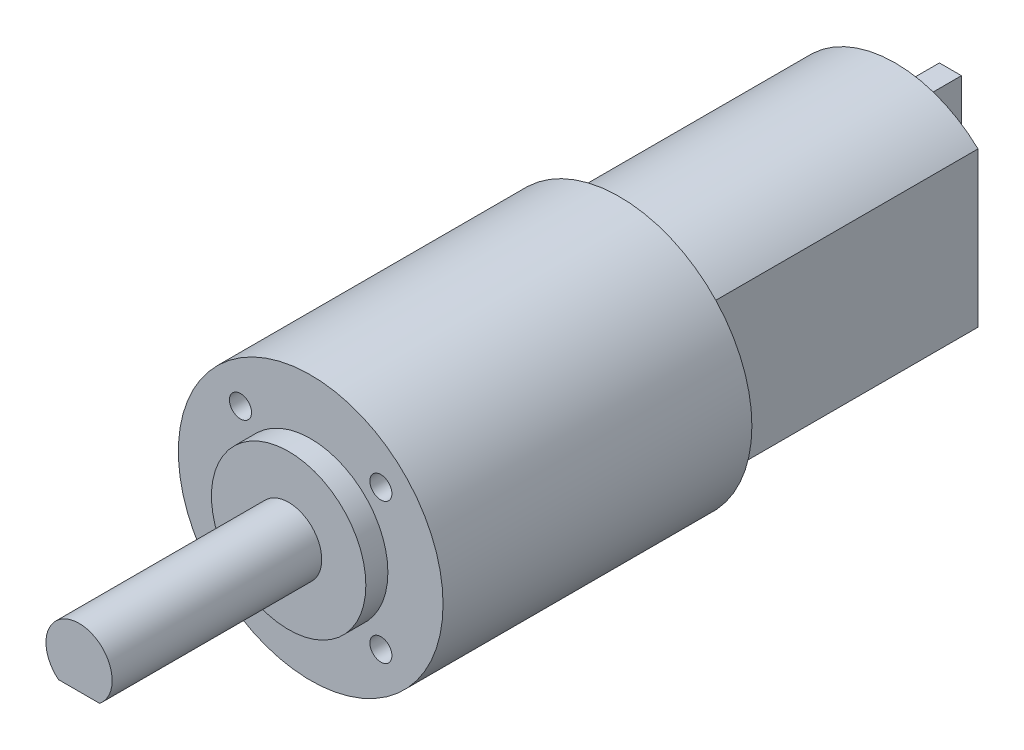
from build123d import *

# Parameters (mm, degrees)
BOSS_EXTRUDE1_DEPTH = 25
SKETCH2_W           = 2
SKETCH2_H           = 4
BOSS_EXTRUDE2_DEPTH = 5
SKETCH3_R           = 12
BOSS_EXTRUDE3_DEPTH = 28
SKETCH4_R           = 7
BOSS_EXTRUDE4_DEPTH = 2
SKETCH5_R           = 1
CUT_EXTRUDE1_DEPTH  = 5
BOSS_EXTRUDE5_DEPTH = 19


with BuildPart() as part:
    # Sketch1 → Boss-Extrude1 (new body)
    with BuildSketch(Plane.XY):
        with BuildLine():
            Line((7.5, -7), (7.5, 7))
            ThreePointArc((7.5, 7), (0, 10), (-7.5, 7))
            Line((-7.5, 7), (-7.5, -7))
            ThreePointArc((-7.5, -7), (0, -10), (7.5, -7))
        make_face()
    extrude(amount=BOSS_EXTRUDE1_DEPTH)

    # Sketch2 → Boss-Extrude2 (add)
    with BuildSketch(Plane(origin=(0, 0, 0), x_dir=(-1, 0, 0), z_dir=(0, 0, -1))):
        with Locations((0, 5)):
            Rectangle(SKETCH2_W, SKETCH2_H)
        with Locations((0, -5)):
            Rectangle(SKETCH2_W, SKETCH2_H)
    extrude(amount=BOSS_EXTRUDE2_DEPTH)

    # Sketch3 → Boss-Extrude3 (add)
    with BuildSketch(Plane.XY.offset(25)):
        Circle(SKETCH3_R)
    extrude(amount=BOSS_EXTRUDE3_DEPTH)

    # Sketch4 → Boss-Extrude4 (add)
    with BuildSketch(Plane.XY.offset(53)):
        Circle(SKETCH4_R)
    extrude(amount=BOSS_EXTRUDE4_DEPTH)

    # Sketch5 → Cut-Extrude1 (cut)
    with BuildSketch(Plane.XY.offset(53)):
        with Locations((-6.363961031, 6.363961031)):
            Circle(SKETCH5_R)
        with Locations((6.363961031, 6.363961031)):
            Circle(SKETCH5_R)
        with Locations((6.363961031, -6.363961031)):
            Circle(SKETCH5_R)
        with Locations((-6.363961031, -6.363961031)):
            Circle(SKETCH5_R)
    extrude(amount=-CUT_EXTRUDE1_DEPTH, mode=Mode.SUBTRACT)

    # Sketch6 → Boss-Extrude5 (add)
    with BuildSketch(Plane.XY.offset(55)):
        with BuildLine():
            Line((-1.857593316, -2.355705218), (1.857593316, -2.355705218))
            ThreePointArc((1.857593316, -2.355705218), (0, 3), (-1.857593316, -2.355705218))
        make_face()
    extrude(amount=BOSS_EXTRUDE5_DEPTH)


solid = part.part
